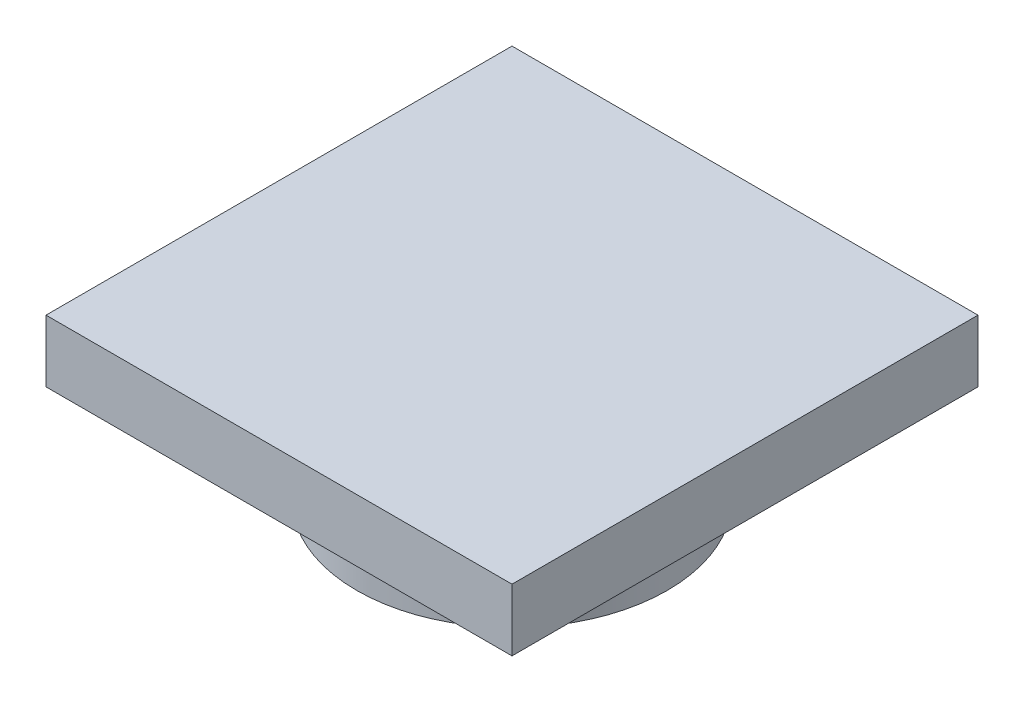
from build123d import *

# Parameters (mm, degrees)
SKETCH1_R           = 5
BOSS_EXTRUDE1_DEPTH = 3.175
SKETCH2_R           = 1
CUT_EXTRUDE1_DEPTH  = 3.175
SKETCH3_W           = 15
SKETCH3_H           = 15
BOSS_EXTRUDE2_DEPTH = 2


with BuildPart() as part:
    # Sketch1 → Boss-Extrude1 (new body)
    with BuildSketch(Plane(origin=(0, 0, 0), x_dir=(1, 0, 0), z_dir=(0, 1, 0))):
        Circle(SKETCH1_R)
    extrude(amount=BOSS_EXTRUDE1_DEPTH)

    # Sketch2 → Cut-Extrude1 (cut)
    with BuildSketch(Plane.XZ):
        Circle(SKETCH2_R)
    extrude(amount=-CUT_EXTRUDE1_DEPTH, mode=Mode.SUBTRACT)

    # Sketch3 → Boss-Extrude2 (add)
    with BuildSketch(Plane(origin=(0, 3.175, 0), x_dir=(1, 0, 0), z_dir=(0, 1, 0))):
        Rectangle(SKETCH3_W, SKETCH3_H)
    extrude(amount=BOSS_EXTRUDE2_DEPTH)


solid = part.part
